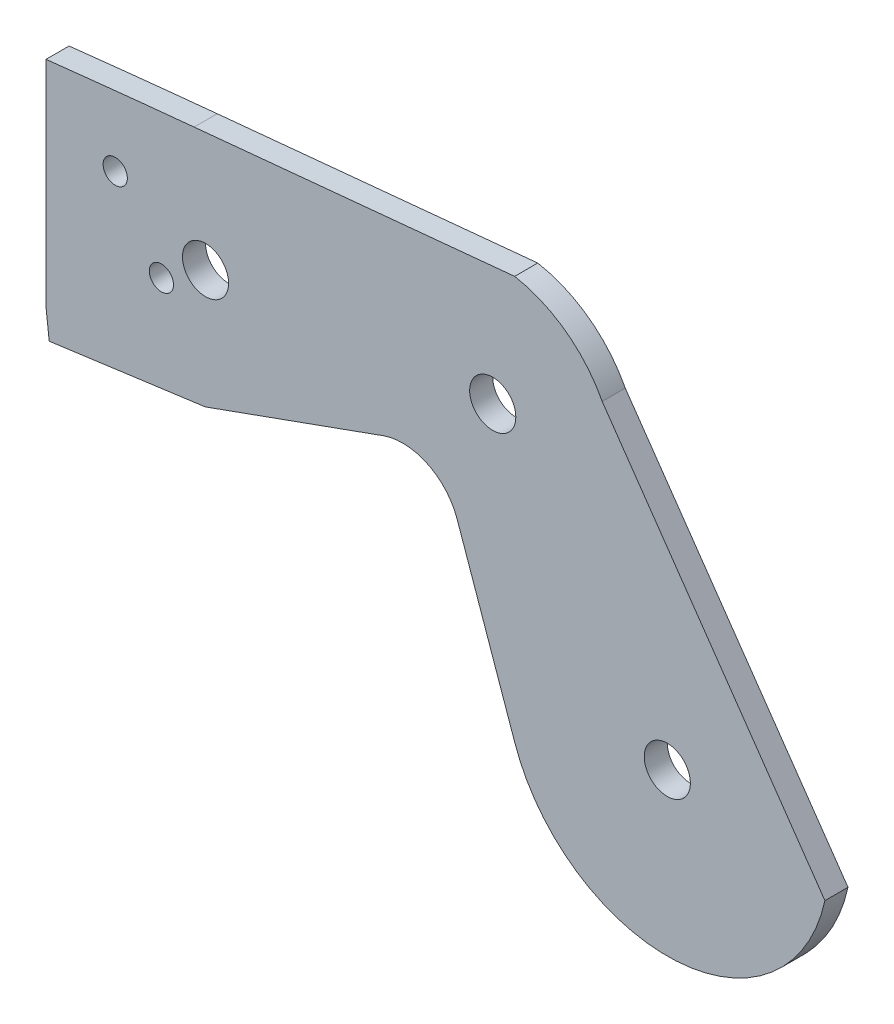
from build123d import *

# Parameters (mm, degrees)
SKETCH_1_R      = 4
SKETCH_1_R_2    = 2.1
EXTRUDE_1_DEPTH = 4


with BuildPart() as part:
    # 草图1 → 凸台-拉伸1 (new body)
    with BuildSketch(Plane.XY):
        with BuildLine():
            Line((27.595444366, 44.436718371), (58.424396384, 55.525816351))
            ThreePointArc((58.424396384, 55.525816351), (66.108542504, 55.144576239), (71.247769486, 49.419212353))
            Line((71.247769486, 49.419212353), (81.175756204, 21.050380059))
            ThreePointArc((81.175756204, 21.050380059), (109.210938469, 2.084714208), (134.977054883, 24.034091663))
            Line((134.977054883, 24.034091663), (96.380255963, 79.649048221))
            ThreePointArc((96.380255963, 79.649048221), (90.097204959, 87.005823858), (81.213704463, 90.837572367))
            Line((81.213704463, 90.837572367), (25.665757334, 85.467931148))
            ThreePointArc((25.665757334, 85.467931148), (12.828050908, 84.180051983), (0, 82.799309813))
            Line((0, 82.799309813), (0, 45.6506733))
            Line((0, 45.6506733), (0.554484915, 40.773047428))
            Line((0.554484915, 40.773047428), (27.595444366, 44.436718371))
        make_face()
        with Locations((27.644326344, 65)):
            Circle(SKETCH_1_R, mode=Mode.SUBTRACT)
        with Locations((107.662812973, 30)):
            Circle(SKETCH_1_R, mode=Mode.SUBTRACT)
        with Locations((77.412339268, 69.810913587)):
            Circle(SKETCH_1_R, mode=Mode.SUBTRACT)
        with Locations((20, 60)):
            Circle(SKETCH_1_R_2, mode=Mode.SUBTRACT)
        with Locations((12, 72)):
            Circle(SKETCH_1_R_2, mode=Mode.SUBTRACT)
    extrude(amount=EXTRUDE_1_DEPTH)


solid = part.part
